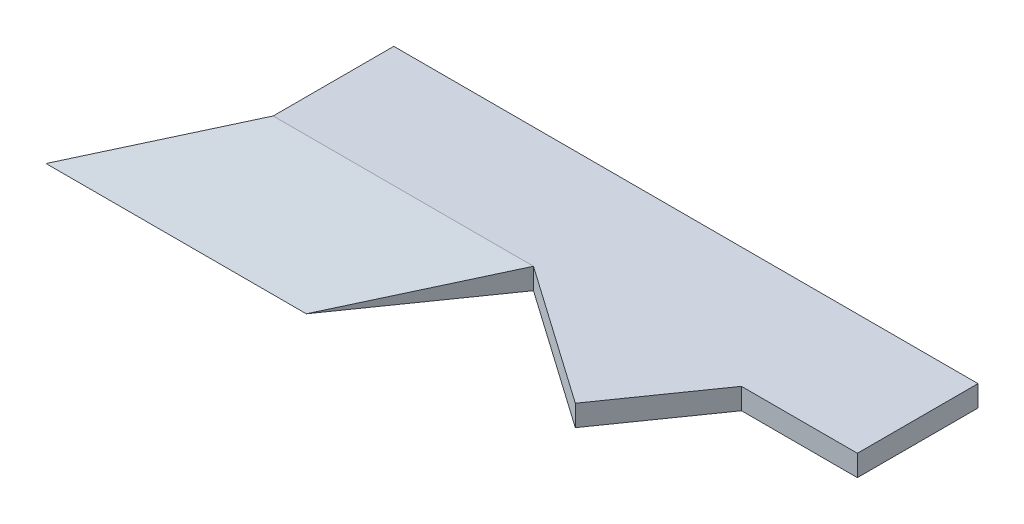
from build123d import *

# Parameters (mm, degrees)
EXTRUDE_1_DEPTH      = 200
EXTRUDE_3_DEPTH      = 1000
EXTRUDE_3_DEPTH_BACK = 2460
CUT_EXTRUDE_1_DEPTH  = 201


with BuildPart() as part:
    # Sketch 1 → Extrude 1 (new body)
    with BuildSketch(Plane(origin=(0, 0, 0), x_dir=(1, 0, 0), z_dir=(0, 1, 0))):
        Polygon((1018.330035249, -1493.454732299), (1664.94, -570), (2760.5, -570), (2760.5, 570), (-2760.5, 570), (-2760.5, -570), (-300.5, -570), align=None)
    extrude(amount=EXTRUDE_1_DEPTH)

    # Sketch 3 → Extrude 3 (add, two sides)
    with BuildSketch(Plane.ZY.offset(2760.5)) as extrude_3_sk:
        Polygon((570, 200), (570, 0), (1832.750302935, 0), align=None)
    extrude(amount=EXTRUDE_3_DEPTH)
    extrude(extrude_3_sk.sketch, amount=-EXTRUDE_3_DEPTH_BACK)

    # Sketch 4 → Cut-Extrude 1 (cut, through all)
    with BuildSketch(Plane(origin=(0, 200, 0), x_dir=(1, 0, 0), z_dir=(0, 1, 0))):
        Polygon((-3760.5, -570), (-2760.5, -570), (-3644.687280992, -1832.750302935), (-3760.5, -1832.750302935), align=None)
        Polygon((-1184.687280992, -1832.750302935), (134.142754257, -2756.205035234), (1018.330035249, -1493.454732299), (-300.5, -570), align=None)
    extrude(amount=-CUT_EXTRUDE_1_DEPTH, mode=Mode.SUBTRACT)


solid = part.part
